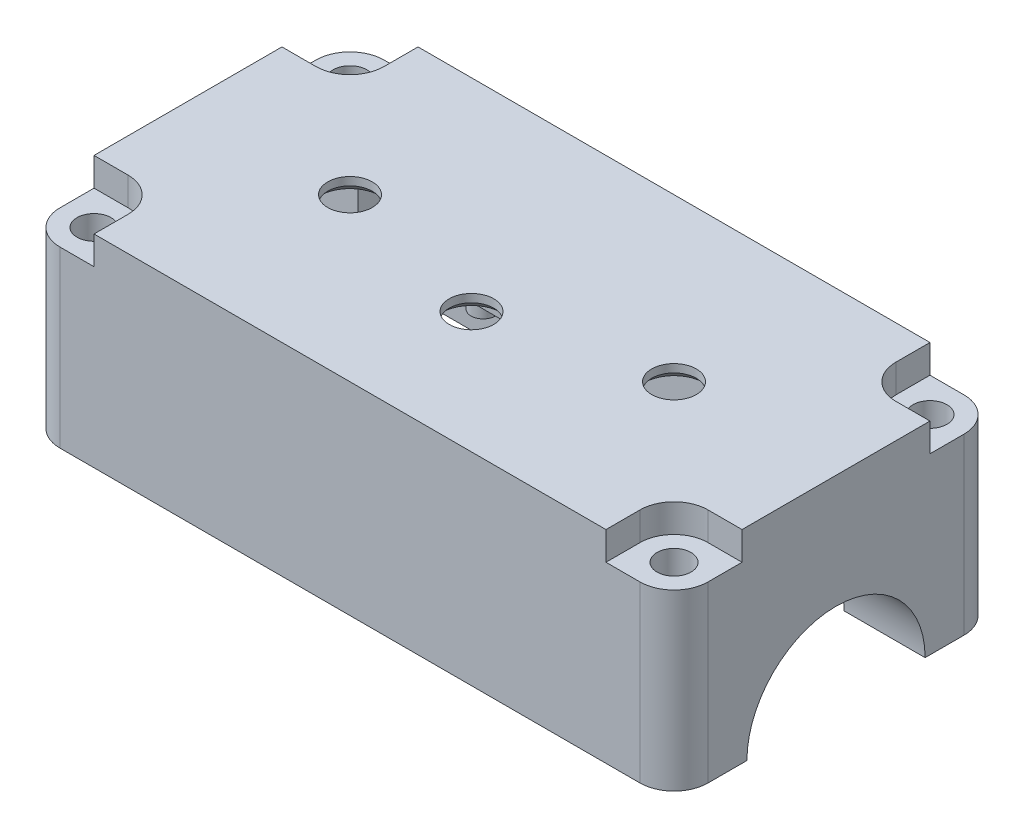
from build123d import *

# Parameters (mm, degrees)
ESQUISSE1_W              = 80
ESQUISSE1_H              = 40
BOSS_EXTRU_1_DEPTH       = 25
ENL_V_MAT_EXTRU_4_DEPTH  = 78
ESQUISSE6_W              = 2
ESQUISSE6_H              = 25
BOSS_EXTRU_3_DEPTH       = 40
ESQUISSE7_R              = 11
ENL_V_MAT_EXTRU_5_DEPTH  = 93.870878105
ESQUISSE8_W              = 60
ESQUISSE8_H              = 36
ENL_V_MAT_EXTRU_6_DEPTH  = 23
ESQUISSE9_W              = 10
ESQUISSE9_H              = 9
BOSS_EXTRU_4_DEPTH       = 23
ESQUISSE10_R             = 2.1
ENL_V_MAT_EXTRU_8_DEPTH  = 93.870878105
ESQUISSE11_R             = 2.75
ENL_V_MAT_EXTRU_9_DEPTH  = 93.870878105
CHANFREIN1_SIZE          = 1
ESQUISSE12_R             = 4.2
ESQUISSE12_R_2           = 2.1
ENL_V_MAT_EXTRU_10_DEPTH = 3.5
CONG_1_R                 = 4.2
ESQUISSE13_W             = 7
ESQUISSE13_H             = 7
BOSS_EXTRU_5_DEPTH       = 3
ESQUISSE14_W             = 20
ESQUISSE14_H             = 2
BOSS_EXTRU_16_DEPTH      = 5
ESQUISSE15_W             = 20
ESQUISSE15_H             = 2
BOSS_EXTRU_17_DEPTH      = 7
ESQUISSE17_W             = 20
ESQUISSE17_H             = 2
BOSS_EXTRU_18_DEPTH      = 11
ESQUISSE18_R             = 1.5
BOSS_EXTRU_19_DEPTH      = 3


with BuildPart() as part:
    # Esquisse1 → Boss.-Extru.1 (new body)
    with BuildSketch(Plane(origin=(0, 0, 0), x_dir=(1, 0, 0), z_dir=(0, 1, 0))):
        with Locations((40, 20)):
            Rectangle(ESQUISSE1_W, ESQUISSE1_H)
    extrude(amount=BOSS_EXTRU_1_DEPTH)

    # Esquisse5 → Enlèv. mat.-Extru.4 (cut)
    with BuildSketch(Plane.ZY):
        with BuildLine():
            Line((-2, 23), (-38, 23))
            Line((-38, 23), (-38, 2))
            Line((-38, 2), (-32.845232579, 2))
            ThreePointArc((-32.845232579, 2), (-20, 13), (-7.154767421, 2))
            Line((-7.154767421, 2), (-2, 2))
            Line((-2, 2), (-2, 23))
        make_face()
    extrude(amount=-ENL_V_MAT_EXTRU_4_DEPTH, mode=Mode.SUBTRACT)

    # Esquisse6 → Boss.-Extru.3 (add)
    with BuildSketch(Plane(origin=(0, 0, -40), x_dir=(-1, 0, 0), z_dir=(0, 0, -1))):
        with Locations((-1, 12.5)):
            Rectangle(ESQUISSE6_W, ESQUISSE6_H)
    extrude(amount=-BOSS_EXTRU_3_DEPTH)

    # Esquisse7 → Enlèv. mat.-Extru.5 (cut, through all)
    with BuildSketch(Plane.ZY):
        with Locations((-20, 0)):
            Circle(ESQUISSE7_R)
    extrude(amount=-ENL_V_MAT_EXTRU_5_DEPTH, mode=Mode.SUBTRACT)

    # Esquisse8 → Enlèv. mat.-Extru.6 (cut)
    with BuildSketch(Plane.XZ):
        with Locations((40, -20)):
            Rectangle(ESQUISSE8_W, ESQUISSE8_H)
    extrude(amount=-ENL_V_MAT_EXTRU_6_DEPTH, mode=Mode.SUBTRACT)

    # Esquisse9 → Boss.-Extru.4 (add)
    with BuildSketch(Plane(origin=(0, 25, 0), x_dir=(1, 0, 0), z_dir=(0, 1, 0))):
        with Locations((75, 4.5)):
            Rectangle(ESQUISSE9_W, ESQUISSE9_H)
        with Locations((5, 4.5)):
            Rectangle(ESQUISSE9_W, ESQUISSE9_H)
        with Locations((5, 35.5)):
            Rectangle(ESQUISSE9_W, ESQUISSE9_H)
        with Locations((75, 35.5)):
            Rectangle(ESQUISSE9_W, ESQUISSE9_H)
    extrude(amount=-BOSS_EXTRU_4_DEPTH)

    # Esquisse10 → Enlèv. mat.-Extru.8 (cut, through all)
    with BuildSketch(Plane(origin=(0, 25, 0), x_dir=(1, 0, 0), z_dir=(0, 1, 0))):
        with Locations(Location((75.8, 35.8, 0), (0, 0, 270))):
            Circle(ESQUISSE10_R)
        with Locations(Location((75.8, 4.2, 0), (0, 0, 270))):
            Circle(ESQUISSE10_R)
        with Locations(Location((4.2, 4.2, 0), (0, 0, 270))):
            Circle(ESQUISSE10_R)
        with Locations(Location((4.2, 35.8, 0), (0, 0, 270))):
            Circle(ESQUISSE10_R)
    extrude(amount=-ENL_V_MAT_EXTRU_8_DEPTH, mode=Mode.SUBTRACT)

    # Esquisse11 → Enlèv. mat.-Extru.9 (cut, through all)
    with BuildSketch(Plane(origin=(0, 25, 0), x_dir=(1, 0, 0), z_dir=(0, 1, 0))):
        with Locations(Location((60, 20, 0), (0, 0, 270))):
            Circle(ESQUISSE11_R)
        with Locations(Location((40, 15, 0), (0, 0, 270))):
            Circle(ESQUISSE11_R)
        with Locations(Location((20, 20, 0), (0, 0, 270))):
            Circle(ESQUISSE11_R)
    extrude(amount=-ENL_V_MAT_EXTRU_9_DEPTH, mode=Mode.SUBTRACT)

    # Chanfrein1
    chanfrein1_edges = [part.edges().sort_by_distance(p)[0] for p in [
        (60, 23, -22.75),
        (40, 23, -17.75),
        (20, 23, -22.75),
    ]]
    chamfer(chanfrein1_edges, length=CHANFREIN1_SIZE)

    # Esquisse12 → Enlèv. mat.-Extru.10 (cut)
    with BuildSketch(Plane(origin=(0, 25, 0), x_dir=(1, 0, 0), z_dir=(0, 1, 0))):
        with BuildLine():
            Line((71.6, 4.2), (71.6, 0))
            Line((71.6, 0), (75.8, 0))
            ThreePointArc((75.8, 0), (72.830151519, 1.230151519), (71.6, 4.2))
        make_face()
        with Locations((75.8, 4.2)):
            Circle(ESQUISSE12_R)
        with Locations(Location((75.8, 4.2, 0), (0, 0, 270))):
            Circle(ESQUISSE12_R_2, mode=Mode.SUBTRACT)
        with BuildLine():
            ThreePointArc((80, 4.2), (78.769848481, 1.230151519), (75.8, 0))
            Line((75.8, 0), (80, 0))
            Line((80, 0), (80, 4.2))
        make_face()
        with BuildLine():
            Line((80, 8.4), (75.8, 8.4))
            ThreePointArc((75.8, 8.4), (78.769848481, 7.169848481), (80, 4.2))
            Line((80, 4.2), (80, 8.4))
        make_face()
        with BuildLine():
            Line((75.8, 31.6), (80, 31.6))
            Line((80, 31.6), (80, 35.8))
            ThreePointArc((80, 35.8), (78.769848481, 32.830151519), (75.8, 31.6))
        make_face()
        with Locations((75.8, 35.8)):
            Circle(ESQUISSE12_R)
        with Locations(Location((75.8, 35.8, 0), (0, 0, 270))):
            Circle(ESQUISSE12_R_2, mode=Mode.SUBTRACT)
        with BuildLine():
            ThreePointArc((75.8, 40), (78.769848481, 38.769848481), (80, 35.8))
            Line((80, 35.8), (80, 40))
            Line((80, 40), (75.8, 40))
        make_face()
        with BuildLine():
            Line((71.6, 40), (71.6, 35.8))
            ThreePointArc((71.6, 35.8), (72.830151519, 38.769848481), (75.8, 40))
            Line((75.8, 40), (71.6, 40))
        make_face()
        with BuildLine():
            Line((0, 35.8), (0, 31.6))
            Line((0, 31.6), (4.2, 31.6))
            ThreePointArc((4.2, 31.6), (1.230151519, 32.830151519), (0, 35.8))
        make_face()
        with Locations((4.2, 35.8)):
            Circle(ESQUISSE12_R)
        with Locations(Location((4.2, 35.8, 0), (0, 0, 270))):
            Circle(ESQUISSE12_R_2, mode=Mode.SUBTRACT)
        with BuildLine():
            Line((0, 40), (0, 35.8))
            ThreePointArc((0, 35.8), (1.230151526, 38.769848488), (4.200000019, 40))
            Line((4.200000019, 40), (0, 40))
        make_face()
        with BuildLine():
            ThreePointArc((4.200000019, 40), (7.169848488, 38.769848474), (8.4, 35.8))
            Line((8.4, 35.8), (8.4, 40))
            Line((8.4, 40), (4.200000019, 40))
        make_face()
        with BuildLine():
            ThreePointArc((0, 4.200000008), (1.230151522, 7.169848484), (4.2, 8.4))
            Line((4.2, 8.4), (0, 8.4))
            Line((0, 8.4), (0, 4.200000008))
        make_face()
        with Locations((4.2, 4.2)):
            Circle(ESQUISSE12_R)
        with Locations(Location((4.2, 4.2, 0), (0, 0, 270))):
            Circle(ESQUISSE12_R_2, mode=Mode.SUBTRACT)
        with BuildLine():
            Line((0, 0), (4.2, 0))
            ThreePointArc((4.2, 0), (1.230151516, 1.230151522), (0, 4.200000008))
            Line((0, 4.200000008), (0, 0))
        make_face()
        with BuildLine():
            Line((4.2, 0), (8.4, 0))
            Line((8.4, 0), (8.4, 4.2))
            ThreePointArc((8.4, 4.2), (7.169848481, 1.230151519), (4.2, 0))
        make_face()
    extrude(amount=-ENL_V_MAT_EXTRU_10_DEPTH, mode=Mode.SUBTRACT)

    # Congé1
    cong_1_edges = [part.edges().sort_by_distance(p)[0] for p in [
        (80, 10.75, 0),
        (80, 10.75, -40),
        (0, 10.75, -40),
        (0, 10.75, 0),
    ]]
    fillet(cong_1_edges, radius=CONG_1_R)

    # Esquisse13 → Boss.-Extru.5 (add)
    with BuildSketch(Plane.XZ.offset(-23)):
        with BuildLine():
            Line((32.45, -21), (47.55, -21))
            ThreePointArc((47.55, -21), (50.55, -24), (47.55, -27))
            Line((47.55, -27), (32.45, -27))
            ThreePointArc((32.45, -27), (29.45, -24), (32.45, -21))
        make_face()
        with Locations((40, -30.5)):
            Rectangle(ESQUISSE13_W, ESQUISSE13_H)
    extrude(amount=BOSS_EXTRU_5_DEPTH)

    # Esquisse14 → Boss.-Extru.16 (add)
    with BuildSketch(Plane.XZ.offset(-23)):
        with Locations((60, -8)):
            Rectangle(ESQUISSE14_W, ESQUISSE14_H)
    extrude(amount=BOSS_EXTRU_16_DEPTH)

    # Esquisse15 → Boss.-Extru.17 (add)
    with BuildSketch(Plane(origin=(0, 0, -2), x_dir=(-1, 0, 0), z_dir=(0, 0, -1))):
        with Locations((-60, 1)):
            Rectangle(ESQUISSE15_W, ESQUISSE15_H)
    extrude(amount=BOSS_EXTRU_17_DEPTH)

    # Esquisse17 → Boss.-Extru.18 (add)
    with BuildSketch(Plane.XZ):
        with Locations((60, -8)):
            Rectangle(ESQUISSE17_W, ESQUISSE17_H)
    extrude(amount=-BOSS_EXTRU_18_DEPTH)

    # Esquisse18 → Boss.-Extru.19 (add)
    with BuildSketch(Plane.XZ.offset(-20)):
        with Locations(Location((32.45, -24, 0), (0, 0, 270))):
            Circle(ESQUISSE18_R)
        with Locations(Location((47.55, -24, 0), (0, 0, 270))):
            Circle(ESQUISSE18_R)
    extrude(amount=BOSS_EXTRU_19_DEPTH)


solid = part.part
